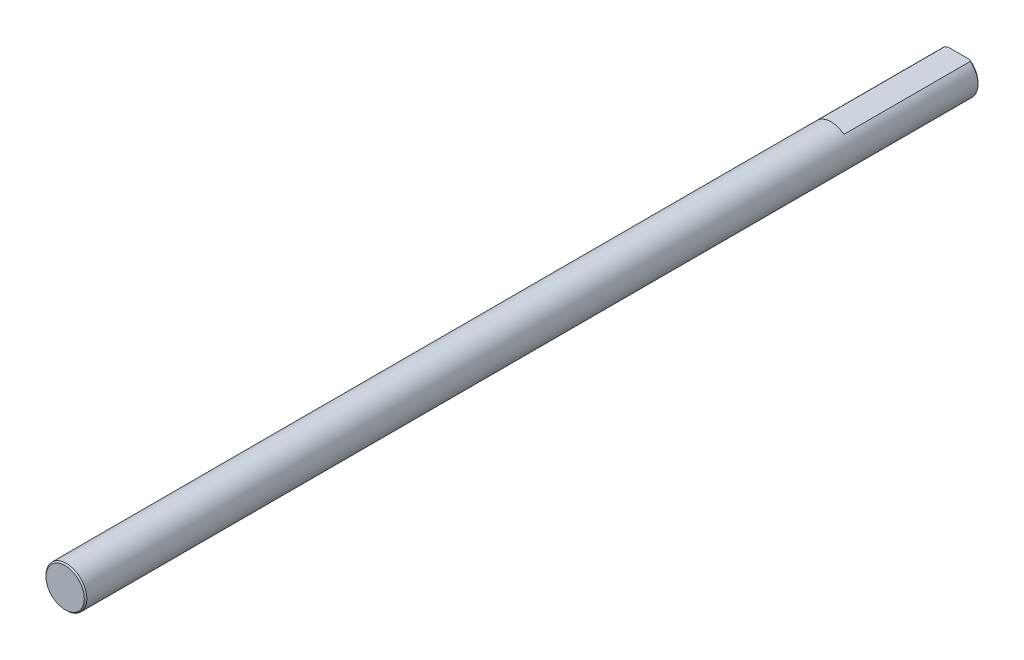
from build123d import *

# Parameters (mm, degrees)
SKETCH1_R               = 1.6
BOSS_EXTRUDE1_DEPTH     = 70
SKETCH2_W               = 10
SKETCH2_H               = 0.35
CUT_EXTRUDE1_DEPTH      = 2.6
CUT_EXTRUDE1_DEPTH_BACK = 2.6
CHAMFER1_SIZE           = 0.1


with BuildPart() as part:
    # Sketch1 → Boss-Extrude1 (new body)
    with BuildSketch(Plane.XY):
        Circle(SKETCH1_R)
    extrude(amount=BOSS_EXTRUDE1_DEPTH)

    # Sketch2 → Cut-Extrude1 (cut, two sides)
    with BuildSketch(Plane(origin=(0, 0, 0), x_dir=(0, 0, -1), z_dir=(1, 0, 0))) as cut_extrude1_sk:
        with Locations((-5, 1.425)):
            Rectangle(SKETCH2_W, SKETCH2_H)
    extrude(amount=CUT_EXTRUDE1_DEPTH, mode=Mode.SUBTRACT)
    extrude(cut_extrude1_sk.sketch, amount=-CUT_EXTRUDE1_DEPTH_BACK, mode=Mode.SUBTRACT)

    # Chamfer1
    chamfer1_edges = [part.edges().sort_by_distance(p)[0] for p in [
        (-1.6, 0, 70),
        (-0.693542087, -1.441873564, 0),
    ]]
    chamfer(chamfer1_edges, length=CHAMFER1_SIZE)


solid = part.part
